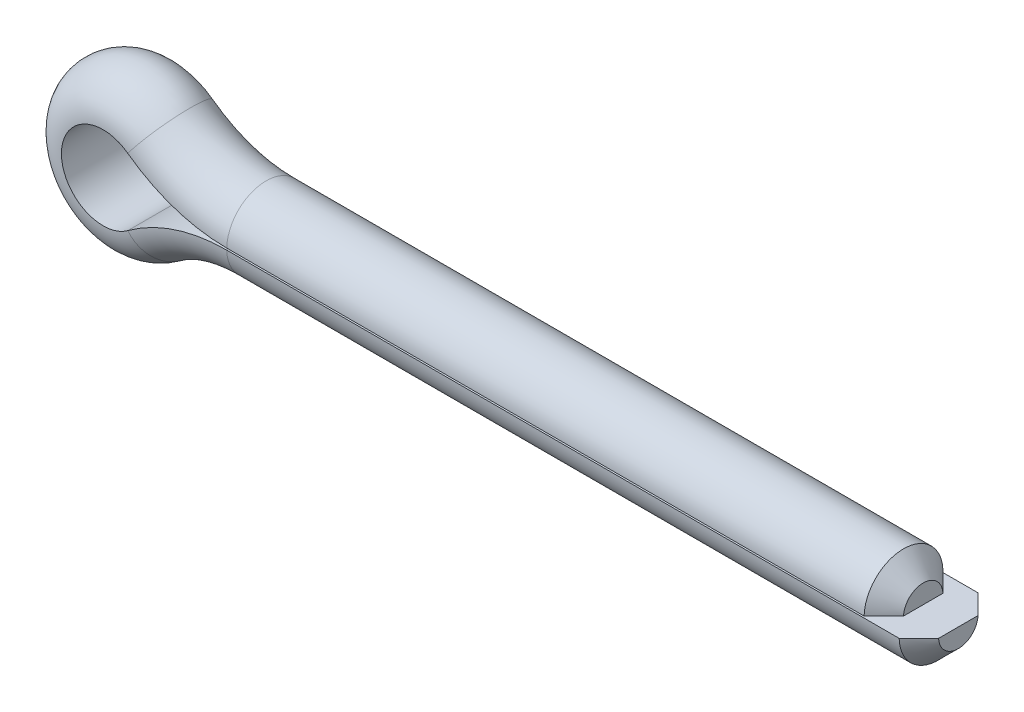
from build123d import *

# Parameters (mm, degrees)
CHAMFER1_SIZE = 0.5715


with BuildPart() as part:
    # Sweep2: sweep along a path in Sketch3
    with BuildLine(Plane.XY) as sweep2_path:
        Line((1.016, -0.0254), (-19.05, -0.0254))
        ThreePointArc((-19.05, -0.0254), (-20.559965377, -0.267702741), (-21.918306738, -0.97028))
        ThreePointArc((-21.918306738, -0.97028), (-23.841883423, 0), (-21.918306738, 0.97028))
        ThreePointArc((-21.918306738, 0.97028), (-20.559965377, 0.267702741), (-19.05, 0.0254))
        Line((-19.05, 0.0254), (0, 0.0254))
    # Sketch4 → Sweep2 (sweep)
    with BuildSketch(Plane(origin=(0, 0, 0), x_dir=(0, 0, -1), z_dir=(1, 0, 0))):
        with BuildLine():
            Line((-1.143, 0.0254), (1.143, 0.0254))
            ThreePointArc((1.143, 0.0254), (0, 1.143), (-1.143, 0.0254))
        make_face()
    sweep(path=sweep2_path.line)

    # Chamfer1
    chamfer1_edges = [part.edges().sort_by_distance(p)[0] for p in [
        (0, 1.143, 0),
        (1.016, -1.143, 0),
    ]]
    chamfer(chamfer1_edges, length=CHAMFER1_SIZE)


solid = part.part
